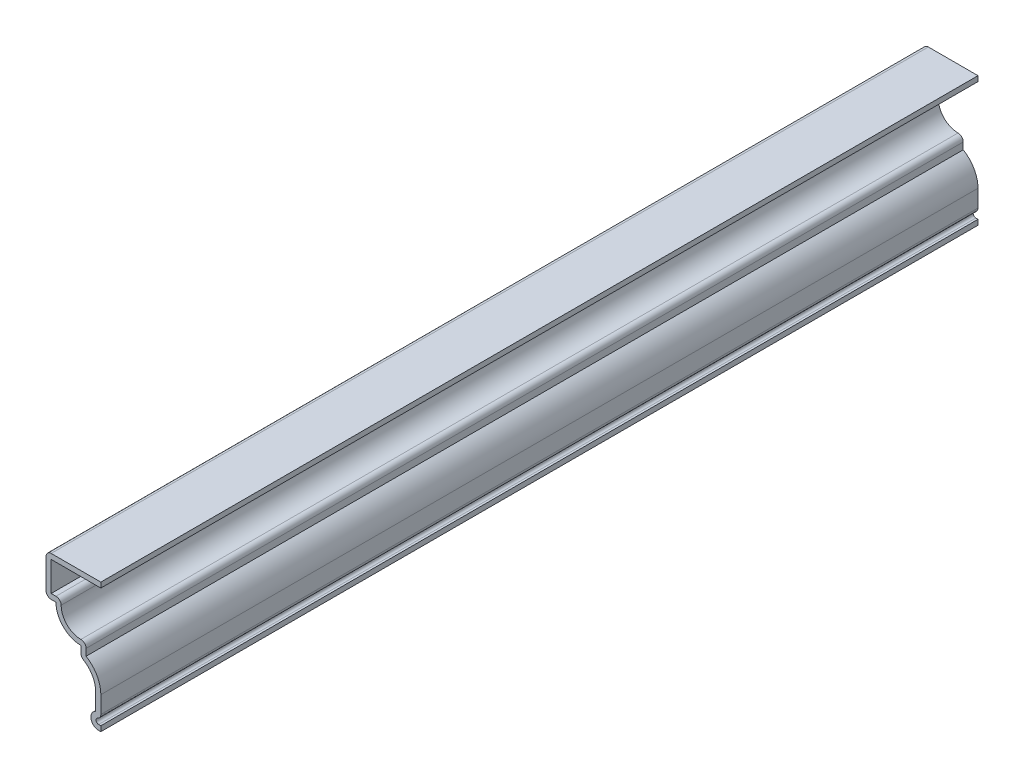
from build123d import *

# Parameters (mm, degrees)
EXTRUDE_THIN2_DEPTH = 279.4
FILLET1_R           = 1.651


with BuildPart() as part:
    # Sketch1 → Extrude-Thin2 (new body)
    with BuildSketch(Plane.XY):
        with BuildLine():
            Line((0, 0), (-0.6985, 0))
            ThreePointArc((-0.6985, 0), (-3.126908, 1.990818), (-1.651, 4.7625))
            Line((-1.651, 4.7625), (-1.651, 10.215706))
            ThreePointArc((-1.651, 10.215706), (-2.928564, 14.534173), (-6.35, 17.4625))
            Line((-6.35, 17.4625), (-6.35, 20.6375))
            ThreePointArc((-6.35, 20.6375), (-11.96266, 22.96234), (-14.2875, 28.575))
            Line((-14.2875, 28.575), (-17.4625, 28.575))
            Line((-17.4625, 28.575), (-17.4625, 41.275))
            Line((-17.4625, 41.275), (0, 41.275))
            Line((0, 41.275), (0, 39.624))
            Line((0, 39.624), (-15.8115, 39.624))
            Line((-15.8115, 39.624), (-15.8115, 30.226))
            Line((-15.8115, 30.226), (-12.415829, 30.226))
            ThreePointArc((-12.415829, 30.226), (-10.795227, 24.129773), (-4.699, 22.509171))
            Line((-4.699, 22.509171), (-4.699, 18.463865))
            ThreePointArc((-4.699, 18.463865), (-1.257164, 14.962092), (0, 10.215706))
            Line((0, 10.215706), (0, 2.916441))
            ThreePointArc((0, 2.916441), (-1.421211, 2.875423), (-0.6985, 1.651))
            Line((-0.6985, 1.651), (0, 1.651))
            Line((0, 1.651), (0, 0))
        make_face()
    extrude(amount=-EXTRUDE_THIN2_DEPTH)

    # Fillet1
    fillet1_edges = [part.edges().sort_by_distance(p)[0] for p in [
        (-12.415829, 30.226, -139.7),
        (-4.699, 22.509171, -139.7),
        (0, 2.916441, -139.7),
        (-6.35, 17.4625, -139.7),
        (-17.4625, 28.575, -139.7),
        (-17.4625, 41.275, -139.7),
    ]]
    fillet(fillet1_edges, radius=FILLET1_R)


solid = part.part
